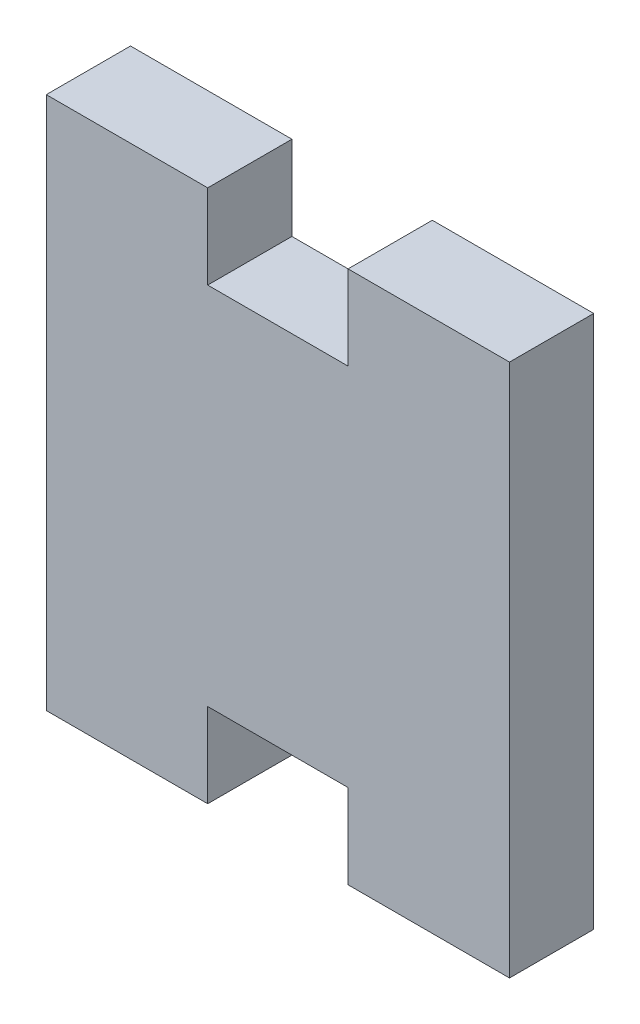
from build123d import *

# Parameters (mm, degrees)
RESSALTO_EXTRUS_O1_DEPTH = 6


with BuildPart() as part:
    # Esboço1 → Ressalto-extrusão1 (new body)
    with BuildSketch(Plane.XY):
        Polygon((-16.5, -13), (-16.5, -19), (-5, -19), (-5, -13), (5, -13), (5, -19), (16.5, -19), (16.5, 19), (5, 19), (5, 13), (-5, 13), (-5, 19), (-16.5, 19), (-16.5, 13), align=None)
    extrude(amount=RESSALTO_EXTRUS_O1_DEPTH)


solid = part.part
